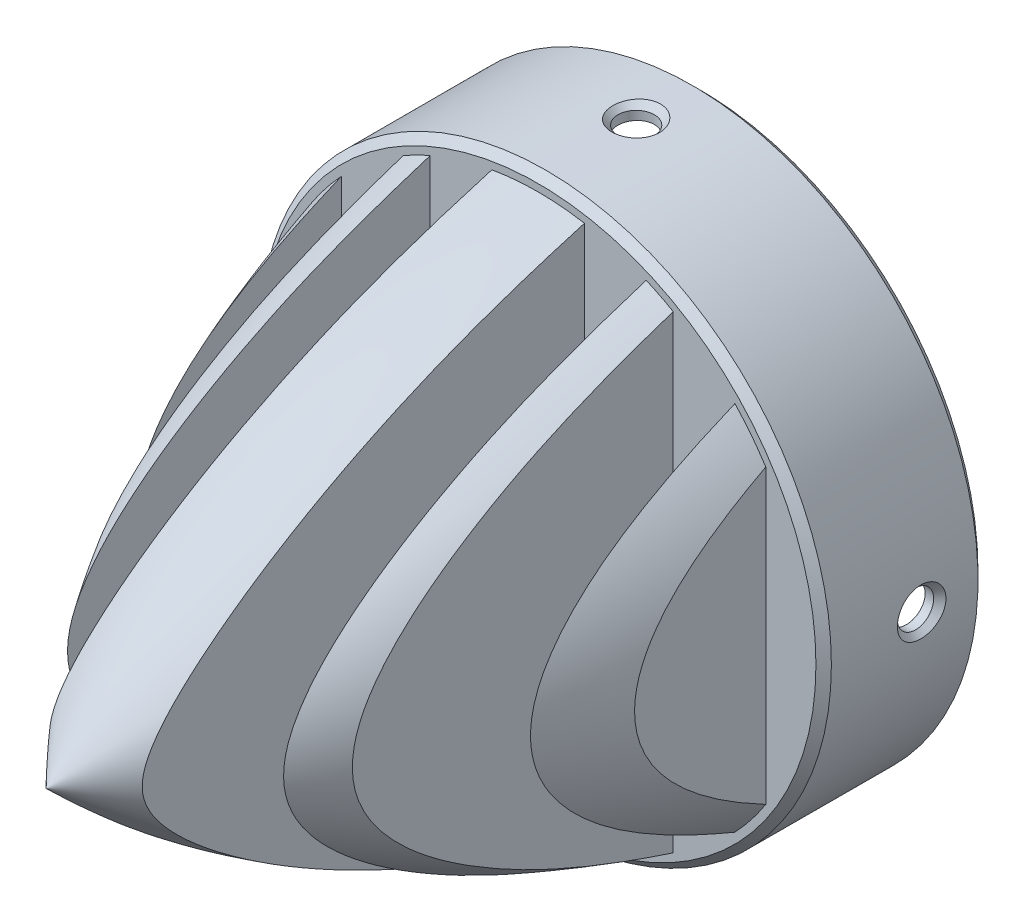
from build123d import *

# Parameters (mm, degrees)
ESQUISSE1_R                  = 37
BOSS_EXTRU_1_DEPTH           = 5
BOSS_EXTRU_2_DEPTH           = 2
BOSS_EXTRU_2_DEPTH_BACK      = 2
ESQUISSE4_R                  = 37
ESQUISSE4_R_2                = 35.1
BOSS_EXTRU_3_DEPTH           = 16
R_P_TITION_CIRCULAIRE1_COUNT = 4
CHANFREIN1_SIZE              = 1
ESQUISSE2_R                  = 3.5
ENL_V_MAT_EXTRU_1_DEPTH      = 10
TROU_TARAUD_M41_D            = 3.3
TROU_TARAUD_M41_DEPTH        = 16
TROU_TARAUD_M41_CSINK_D      = 4.05
TROU_TARAUD_M41_CSINK_ANGLE  = 90
TROU_TARAUD_M41_TIP          = 0.991420021
ENL_V_START                  = -5
ESQUISSE16_W                 = 8
ESQUISSE16_H                 = 94.02813084
ESQUISSE16_H_2               = 73.8048638
ESQUISSE16_W_2               = 25.002890819
ESQUISSE16_H_3               = 63.725671649
ENL_V_MAT_EXTRU_2_DEPTH      = 70


with BuildPart() as part:
    # Esquisse1 → Boss.-Extru.1 (new body)
    with BuildSketch(Plane.XY):
        Circle(ESQUISSE1_R)
    extrude(amount=BOSS_EXTRU_1_DEPTH)

    # Esquisse3 → Boss.-Extru.2 (add, two sides)
    with BuildSketch(Plane(origin=(0, 0, 0), x_dir=(0, 0, -1), z_dir=(1, 0, 0))) as boss_extru_2_sk:
        with BuildLine():
            Line((-0.955147165, 31.61228695), (-0.955147165, -31.61228695))
            add(Edge.make_bspline(
                [(-0.955147165, -31.61228695), (-10.414665374, -29.507161978), (-22.250003976, -24.843629397), (-35.908176545, -18.539904117), (-42.298949985, -14.870509707), (-47.332560559, -11.767973621), (-51.330924788, -9.119867978), (-55.216619007, -5.679621891), (-57.081322145, -2.521472051), (-56.961313186, 0)],
                knots=[0, 0, 0, 0, 0.434307319, 0.573593126, 0.678266475, 0.766557202, 0.840531534, 0.89428957, 1, 1, 1, 1], degree=3))
            add(Edge.make_bspline(
                [(-0.955147165, 31.61228695), (-10.414665374, 29.507161978), (-22.250003976, 24.843629397), (-35.908176545, 18.539904117), (-42.298949985, 14.870509707), (-47.332560559, 11.767973621), (-51.330924788, 9.119867978), (-55.216619007, 5.679621891), (-57.081322145, 2.521472051), (-56.961313186, 0)],
                knots=[0, 0, 0, 0, 0.434307319, 0.573593126, 0.678266475, 0.766557202, 0.840531534, 0.89428957, 1, 1, 1, 1], degree=3))
        make_face()
    extrude(amount=BOSS_EXTRU_2_DEPTH)
    extrude(boss_extru_2_sk.sketch, amount=-BOSS_EXTRU_2_DEPTH_BACK)

    # Esquisse4 → Boss.-Extru.3 (add)
    with BuildSketch(Plane(origin=(0, 0, 0), x_dir=(-1, 0, 0), z_dir=(0, 0, -1))):
        Circle(ESQUISSE4_R)
        Circle(ESQUISSE4_R_2, mode=Mode.SUBTRACT)
    extrude(amount=BOSS_EXTRU_3_DEPTH)

    # Esquisse7 → Trou pour M3 Ensat 302 Al _aluminium_2 (revolve, cut)
    with BuildSketch(Plane(origin=(37, 0, -7.7), x_dir=(0, 0, -1), z_dir=(0, 1, 0))):
        Polygon((0, 0), (0, 11.412022455), (2.35, 10), (2.35, 0.8), (3.15, 0), align=None)
    trou_pour_m3_ensat_302_al_aluminium_2 = revolve(axis=Axis((43.35, 0, -7.7), (-1, 0, 0)), mode=Mode.SUBTRACT)

    # R_p_tition circulaire1: Trou pour M3 Ensat 302 Al _aluminium_2 ×4 about axis
    r_p_tition_circulaire1_axis = Axis((0, 0, 60.735388252), (0, 0, -1))
    for i in range(1, R_P_TITION_CIRCULAIRE1_COUNT):
        add(trou_pour_m3_ensat_302_al_aluminium_2.rotate(r_p_tition_circulaire1_axis, i * 360 / R_P_TITION_CIRCULAIRE1_COUNT), mode=Mode.SUBTRACT)

    # Esquisse11 → R_volution1 (revolve)
    with BuildSketch(Plane(origin=(0, 0, 0), x_dir=(0, 0, -1), z_dir=(1, 0, 0)), mode=Mode.PRIVATE) as r_volution1_sk:
        with BuildLine():
            Line((0, 29.916058824), (-5, 35.055801318))
            add(Edge.make_bspline(
                [(-5, 35.055801318), (-11.131861152, 33.306198176), (-19.46046585, 30.670828749), (-32.023239756, 25.391356571), (-41.828146671, 20.505516246), (-51.345347306, 14.584464988), (-57.403231382, 10.141349982), (-62.952910205, 5.523495251), (-66.341409867, 2.374809563), (-68.781804014, 0)],
                knots=[0, 0, 0, 0, 0.260071139, 0.355265283, 0.555282647, 0.705792825, 0.811597365, 0.861194205, 1, 1, 1, 1], degree=3))
            Line((-68.781804014, 0), (0, 0))
            Line((0, 0), (0, 29.916058824))
        make_face()
    revolve(r_volution1_sk.sketch.rotate(Axis((0, 0, 131.432701229), (0, 0, -1)), 270), axis=Axis((0, 0, 131.432701229), (0, 0, -1)))  # turned: the seam where the file's is

    # Chanfrein1
    chanfrein1_edges = [part.edges().sort_by_distance(p)[0] for p in [
        (37, 0, -16),
        (-37, 0, 5),
    ]]
    chamfer(chanfrein1_edges, length=CHANFREIN1_SIZE)

    # Esquisse2 → Enl_v. mat.-Extru.1 (cut)
    with BuildSketch(Plane.XY.offset(5)):
        with Locations((-21, 0)):
            Circle(ESQUISSE2_R)
        with Locations((-10.5, -18.186533479)):
            Circle(ESQUISSE2_R)
        with Locations((10.5, -18.186533479)):
            Circle(ESQUISSE2_R)
    extrude(amount=-ENL_V_MAT_EXTRU_1_DEPTH, mode=Mode.SUBTRACT)

    # Trou taraud_ M41
    with Locations(Plane.XZ.offset(37)):
        with Locations((0, 7.61)):
            CounterSinkHole(TROU_TARAUD_M41_D / 2, TROU_TARAUD_M41_CSINK_D / 2, depth=TROU_TARAUD_M41_DEPTH, counter_sink_angle=TROU_TARAUD_M41_CSINK_ANGLE)
            with Locations((0, 0, -(TROU_TARAUD_M41_DEPTH + TROU_TARAUD_M41_TIP / 2))):  # 118° drill point
                Cone(0, TROU_TARAUD_M41_D / 2, TROU_TARAUD_M41_TIP, mode=Mode.SUBTRACT)

    # Esquisse16 → Enl_v. mat.-Extru.2 (cut)
    with BuildSketch(Plane(origin=(0, 0, 0), x_dir=(-1, 0, 0), z_dir=(0, 0, -1)).offset(ENL_V_START)):
        with Locations((10, -6.510256034)):
            Rectangle(ESQUISSE16_W, ESQUISSE16_H)
        with Locations((21.5, 2.002478329)):
            Rectangle(ESQUISSE16_W, ESQUISSE16_H_2)
        with Locations((42.00144541, 4.103415525)):
            Rectangle(ESQUISSE16_W_2, ESQUISSE16_H_3)
        with Locations((-42.00144541, 4.103415525)):
            Rectangle(ESQUISSE16_W_2, ESQUISSE16_H_3)
        with Locations((-21.5, 2.002478329)):
            Rectangle(ESQUISSE16_W, ESQUISSE16_H_2)
        with Locations((-10, -6.510256034)):
            Rectangle(ESQUISSE16_W, ESQUISSE16_H)
    extrude(amount=-ENL_V_MAT_EXTRU_2_DEPTH, mode=Mode.SUBTRACT)


solid = part.part
